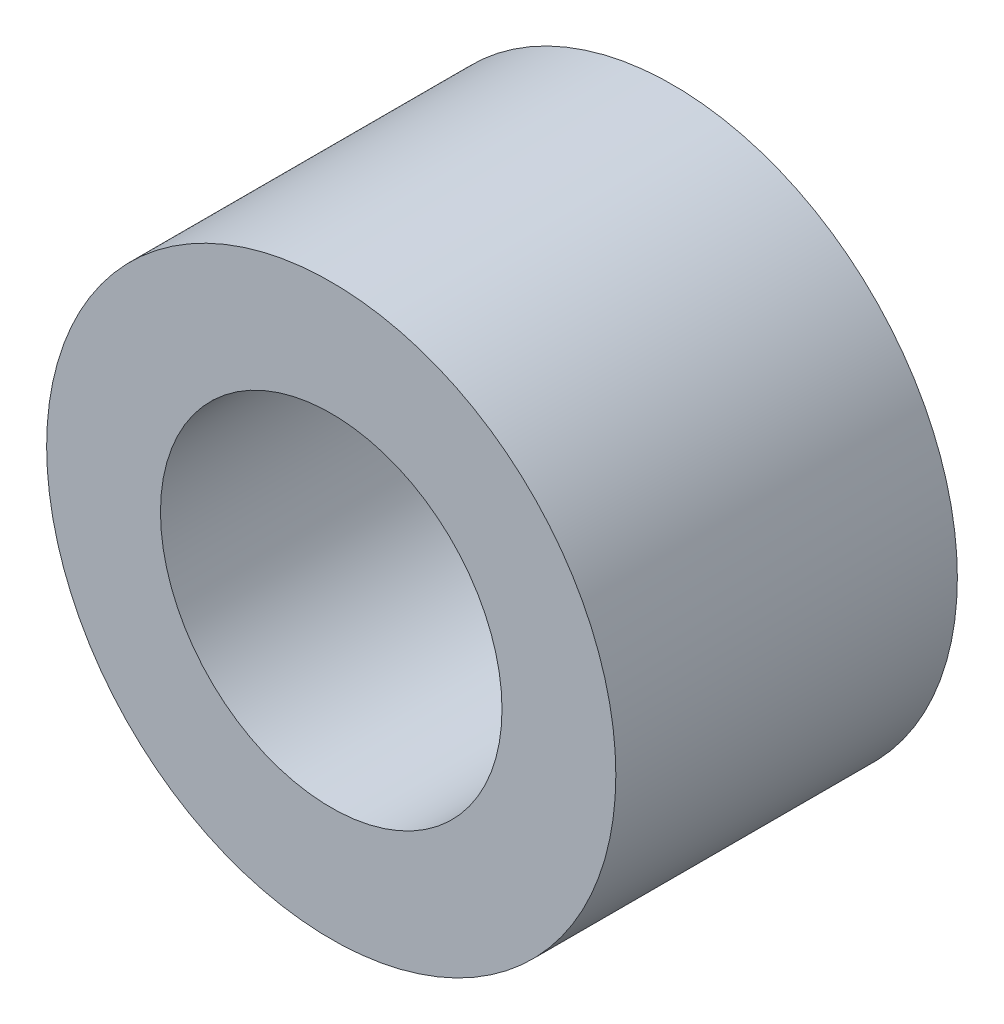
from build123d import *

# Parameters (mm, degrees)
SKETCH3_R           = 7.9375
SKETCH3_R_2         = 4.7625
BOSS_EXTRUDE1_DEPTH = 4.7625


with BuildPart() as part:
    # Sketch3 → Boss-Extrude1 (new body, symmetric)
    with BuildSketch(Plane.XY):
        Circle(SKETCH3_R)
        Circle(SKETCH3_R_2, mode=Mode.SUBTRACT)
    extrude(amount=BOSS_EXTRUDE1_DEPTH, both=True)


solid = part.part
